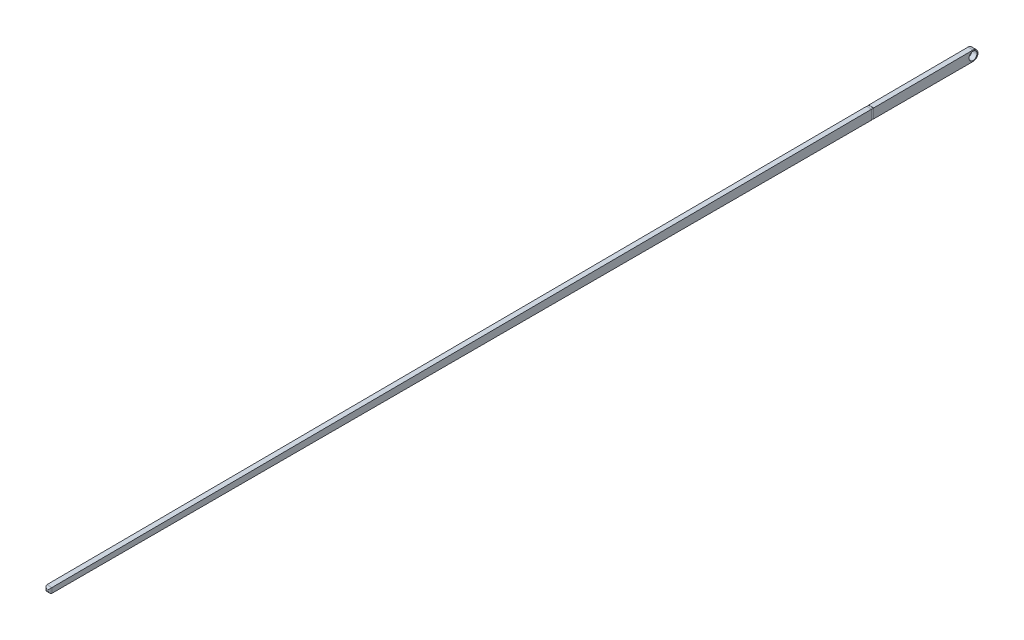
from build123d import *

# Parameters (mm, degrees)
SKETCH2_R           = 0.508
BOSS_EXTRUDE1_DEPTH = 0.3175
FILLET1_R           = 0.254
SKETCH3_W           = 1.016
SKETCH3_H           = 1.524
SKETCH3_W_2         = 0.6096
SKETCH3_H_2         = 1.15018662
CUT_EXTRUDE1_DEPTH  = 0.127


with BuildPart() as part:
    # Sketch2 → Boss-Extrude1 (new body, symmetric)
    with BuildSketch(Plane(origin=(0, 0, 0), x_dir=(0, 0, -1), z_dir=(1, 0, 0))):
        with BuildLine():
            Line((0, -0.635), (-116.84, -0.635))
            Line((-116.84, -0.635), (-116.84, 0))
            Line((-116.84, 0), (-0.003451087, 0.634990622))
            ThreePointArc((-0.003451087, 0.634990622), (0.634997655, 0.00172555), (0, -0.635))
        make_face()
        Circle(SKETCH2_R, mode=Mode.SUBTRACT)
    extrude(amount=BOSS_EXTRUDE1_DEPTH, both=True)

    # Fillet1
    fillet1_edges = [part.edges().sort_by_distance(p)[0] for p in [
        (0.3175, -0.3175, 116.84),
        (-0.3175, -0.3175, 116.84),
        (0, -0.635, 116.84),
        (0, 0, 116.84),
    ]]
    fillet(fillet1_edges, radius=FILLET1_R)

    # Sketch3 → Cut-Extrude1 (cut, symmetric)
    with BuildSketch(Plane.XY.offset(12.7)):
        with Locations((0, -0.03450669)):
            Rectangle(SKETCH3_W, SKETCH3_H)
        with Locations((0, -0.03450669)):
            Rectangle(SKETCH3_W_2, SKETCH3_H_2, mode=Mode.SUBTRACT)
    extrude(amount=CUT_EXTRUDE1_DEPTH, both=True, mode=Mode.SUBTRACT)


solid = part.part
